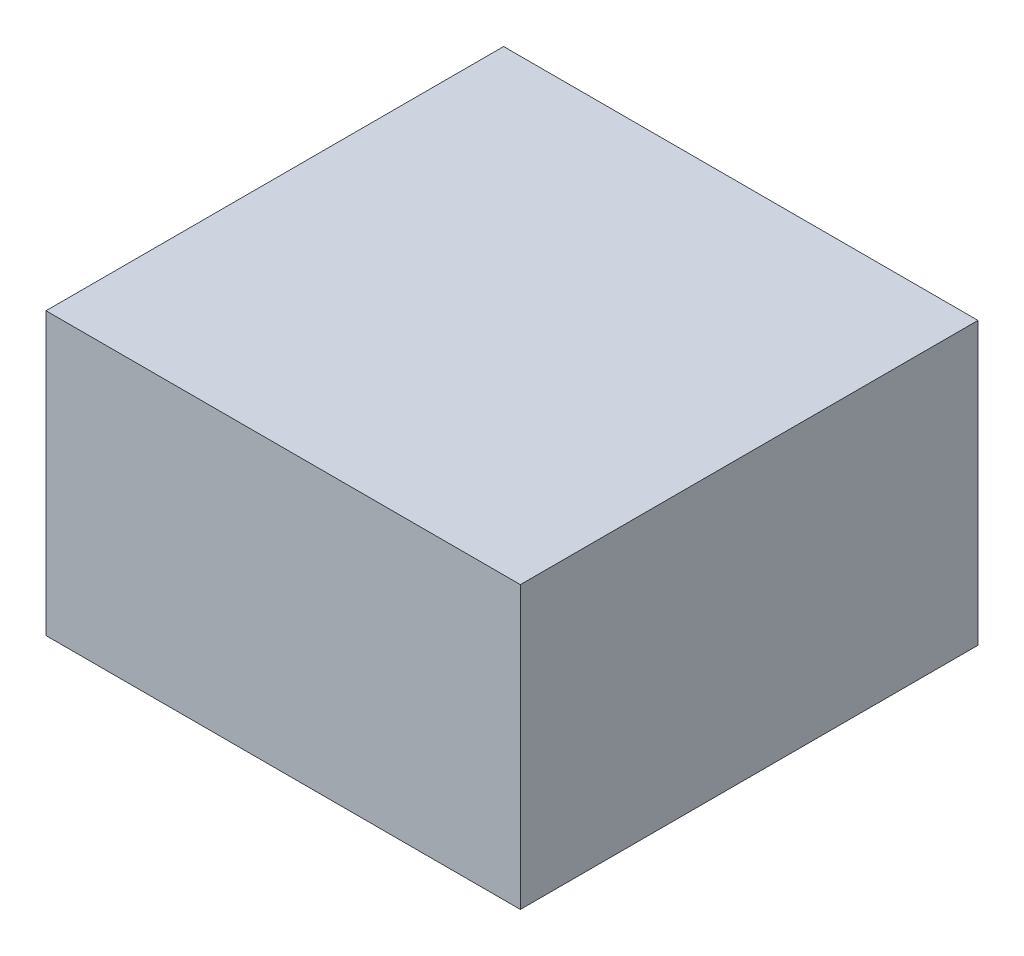
from build123d import *

# Parameters (mm, degrees)
SKETCH1_W    = 425
SKETCH1_H    = 410
BOTTOM_DEPTH = 3.175
SKETCH2_W    = 425
SKETCH2_H    = 410
SKETCH2_W_2  = 420.428
SKETCH2_H_2  = 405.428
SKETCH2_W_3  = 2.286
SKETCH2_H_3  = 201.571
SKETCH2_W_4  = 209.071
SKETCH2_H_4  = 2.286
SIDES_DEPTH  = 246.6
SKETCH3_W    = 425
SKETCH3_H    = 410
TOP_DEPTH    = 2.286


with BuildPart() as part:
    # Sketch1 → Bottom (new body)
    with BuildSketch(Plane(origin=(0, 0, 0), x_dir=(1, 0, 0), z_dir=(0, 1, 0))):
        Rectangle(SKETCH1_W, SKETCH1_H)
    extrude(amount=BOTTOM_DEPTH)

    # Sketch2 → Sides (add)
    with BuildSketch(Plane(origin=(0, 3.175, 0), x_dir=(1, 0, 0), z_dir=(0, 1, 0))):
        Rectangle(SKETCH2_W, SKETCH2_H)
        Rectangle(SKETCH2_W_2, SKETCH2_H_2, mode=Mode.SUBTRACT)
        with Locations((0, 101.9285)):
            Rectangle(SKETCH2_W_3, SKETCH2_H_3)
        with Locations((105.6785, 0)):
            Rectangle(SKETCH2_W_4, SKETCH2_H_4)
        with Locations((0, -101.9285)):
            Rectangle(SKETCH2_W_3, SKETCH2_H_3)
        Rectangle(SKETCH2_W_3, SKETCH2_H_4)
        with Locations((-105.6785, 0)):
            Rectangle(SKETCH2_W_4, SKETCH2_H_4)
    extrude(amount=SIDES_DEPTH)

    # Sketch3 → Top (add)
    with BuildSketch(Plane(origin=(0, 249.775, 0), x_dir=(1, 0, 0), z_dir=(0, 1, 0))):
        Rectangle(SKETCH3_W, SKETCH3_H)
    extrude(amount=TOP_DEPTH)


solid = part.part
